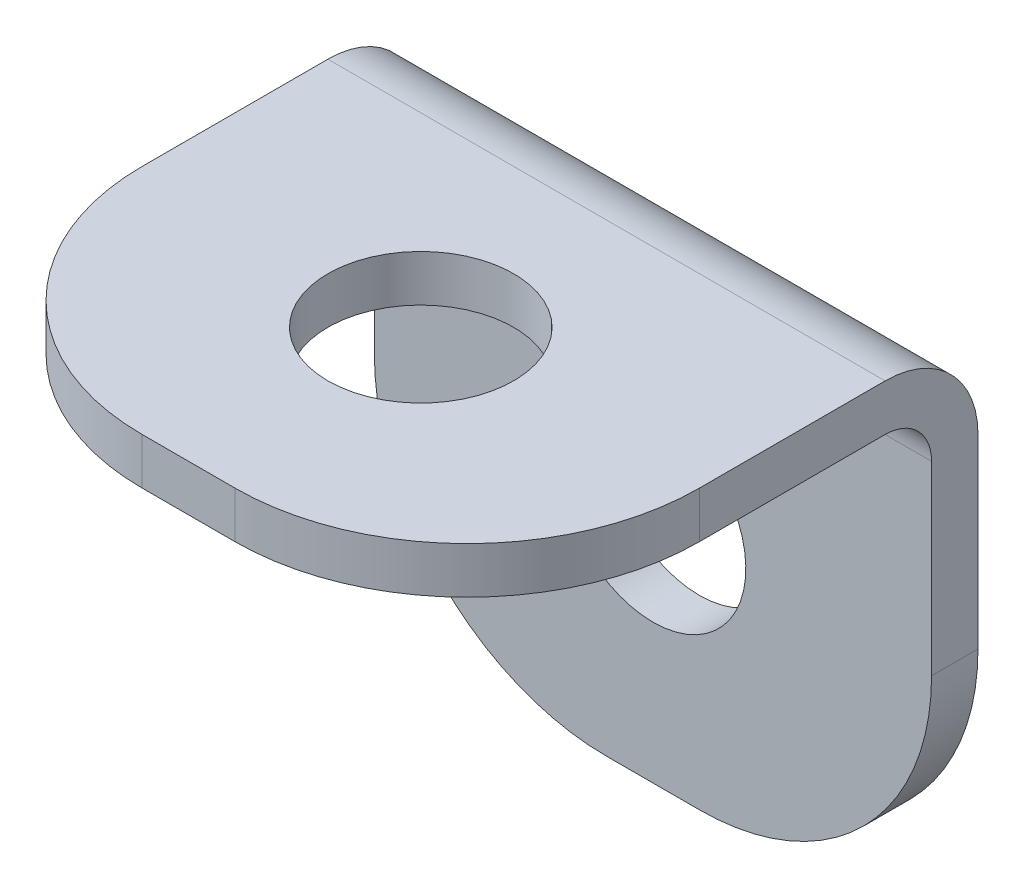
from build123d import *

# Parameters (mm, degrees)
SKETCH1_R      = 2
EXTRUDE1_DEPTH = 1
FILLET2_R      = 1
FILLET3_R      = 2


with BuildPart() as part:
    # Sketch1 → Extrude1 (new body)
    with BuildSketch(Plane(origin=(0, 0, 0), x_dir=(1, 0, 0), z_dir=(0, 1, 0))):
        with BuildLine():
            Line((-6, 0), (-6, 1))
            Line((-6, 1), (6, 1))
            Line((6, 1), (6, 0))
            Line((6, 0), (6, -5))
            ThreePointArc((6, -5), (4.535533906, -8.535533906), (1, -10))
            Line((1, -10), (-1, -10))
            ThreePointArc((-1, -10), (-4.535533906, -8.535533906), (-6, -5))
            Line((-6, -5), (-6, 0))
        make_face()
        with Locations(Location((0, -5, 0), (0, 0, 270))):  # turned: the seam where the file's is
            Circle(SKETCH1_R, mode=Mode.SUBTRACT)
    extrude1 = extrude(amount=EXTRUDE1_DEPTH)

    # Mirror2: Extrude1 across plane
    add(extrude1.mirror(Plane(origin=(0, 0, 0), x_dir=(0, -0.707106781, 0.707106781), z_dir=(0, -0.707106781, -0.707106781))))

    # Fillet2
    fillet2_edges = [part.edges().sort_by_distance(p)[0] for p in [
        (0, 0, 0),
    ]]
    fillet(fillet2_edges, radius=FILLET2_R)

    # Fillet3
    fillet3_edges = [part.edges().sort_by_distance(p)[0] for p in [
        (0, 1, -1),
    ]]
    fillet(fillet3_edges, radius=FILLET3_R)


solid = part.part
